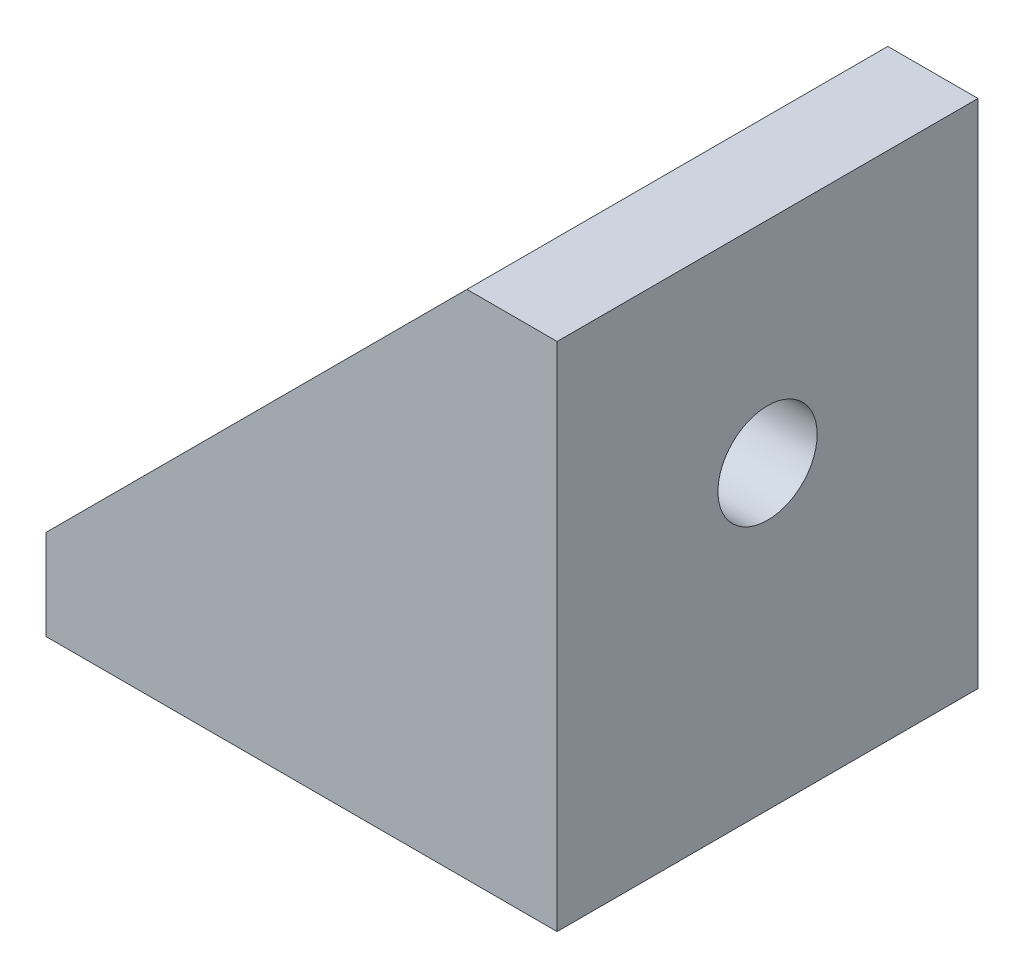
from build123d import *

# Parameters (mm, degrees)
SKETCH1_W           = 14
SKETCH1_H           = 14
SKETCH1_R           = 1.75
BOSS_EXTRUDE1_DEPTH = 3
SKETCH2_W           = 14
SKETCH2_H           = 17
SKETCH2_R           = 1.65
BOSS_EXTRUDE2_DEPTH = 3
BOSS_EXTRUDE3_DEPTH = 2
BOSS_EXTRUDE4_DEPTH = 2


with BuildPart() as part:
    # Sketch1 → Boss-Extrude1 (new body)
    with BuildSketch(Plane(origin=(0, 0, 0), x_dir=(1, 0, 0), z_dir=(0, 1, 0))):
        with Locations((-7, 7)):
            Rectangle(SKETCH1_W, SKETCH1_H)
        with Locations((-7, 7)):
            Circle(SKETCH1_R, mode=Mode.SUBTRACT)
    extrude(amount=BOSS_EXTRUDE1_DEPTH)

    # Sketch2 → Boss-Extrude2 (add)
    with BuildSketch(Plane(origin=(0, 0, 0), x_dir=(0, 0, -1), z_dir=(1, 0, 0))):
        with Locations((7, 8.5)):
            Rectangle(SKETCH2_W, SKETCH2_H)
        with Locations((7, 10)):
            Circle(SKETCH2_R, mode=Mode.SUBTRACT)
    extrude(amount=BOSS_EXTRUDE2_DEPTH)

    # Sketch3 → Boss-Extrude3 (add)
    with BuildSketch(Plane.XY):
        Polygon((0, 3), (0, 17), (-14, 3), align=None)
    extrude(amount=-BOSS_EXTRUDE3_DEPTH)

    # Sketch4 → Boss-Extrude4 (add)
    with BuildSketch(Plane(origin=(0, 0, -14), x_dir=(-1, 0, 0), z_dir=(0, 0, -1))):
        Polygon((0, 3), (14, 3), (0, 17), align=None)
    extrude(amount=-BOSS_EXTRUDE4_DEPTH)


solid = part.part
